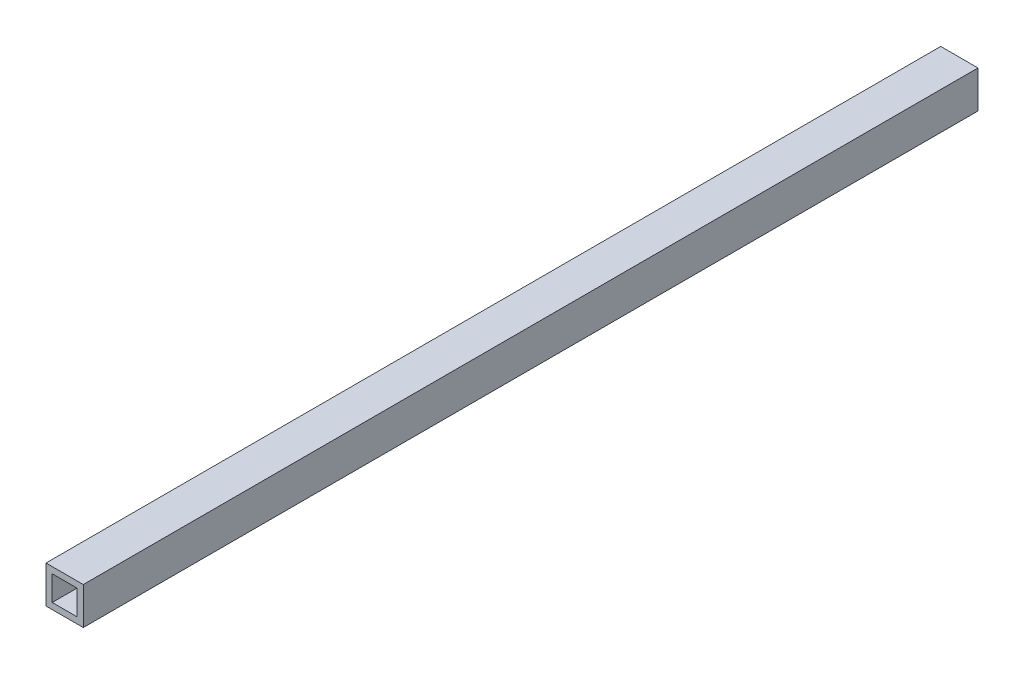
from build123d import *

# Parameters (mm, degrees)
SKETCH1_W           = 19.05
SKETCH1_H           = 19.05
BOSS_EXTRUDE1_DEPTH = 457.2
CUT_EXTRUDE1_REACH  = 459.2
SKETCH2_W           = 12.7
SKETCH2_H           = 12.7


with BuildPart() as part:
    # Sketch1 → Boss-Extrude1 (new body)
    with BuildSketch(Plane.XY):
        Rectangle(SKETCH1_W, SKETCH1_H)
    extrude(amount=-BOSS_EXTRUDE1_DEPTH)

    # Sketch2 → Cut-Extrude1 (cut, up to next)
    with BuildSketch(Plane.XY, mode=Mode.PRIVATE) as cut_extrude1_sk1:
        Rectangle(SKETCH2_W, SKETCH2_H)
    cut_extrude1_tool1 = extrude(cut_extrude1_sk1.sketch, amount=-CUT_EXTRUDE1_REACH, mode=Mode.PRIVATE) & part.part
    add(cut_extrude1_tool1.solids().sort_by_distance((0, 0, 0))[0], mode=Mode.SUBTRACT)


solid = part.part
